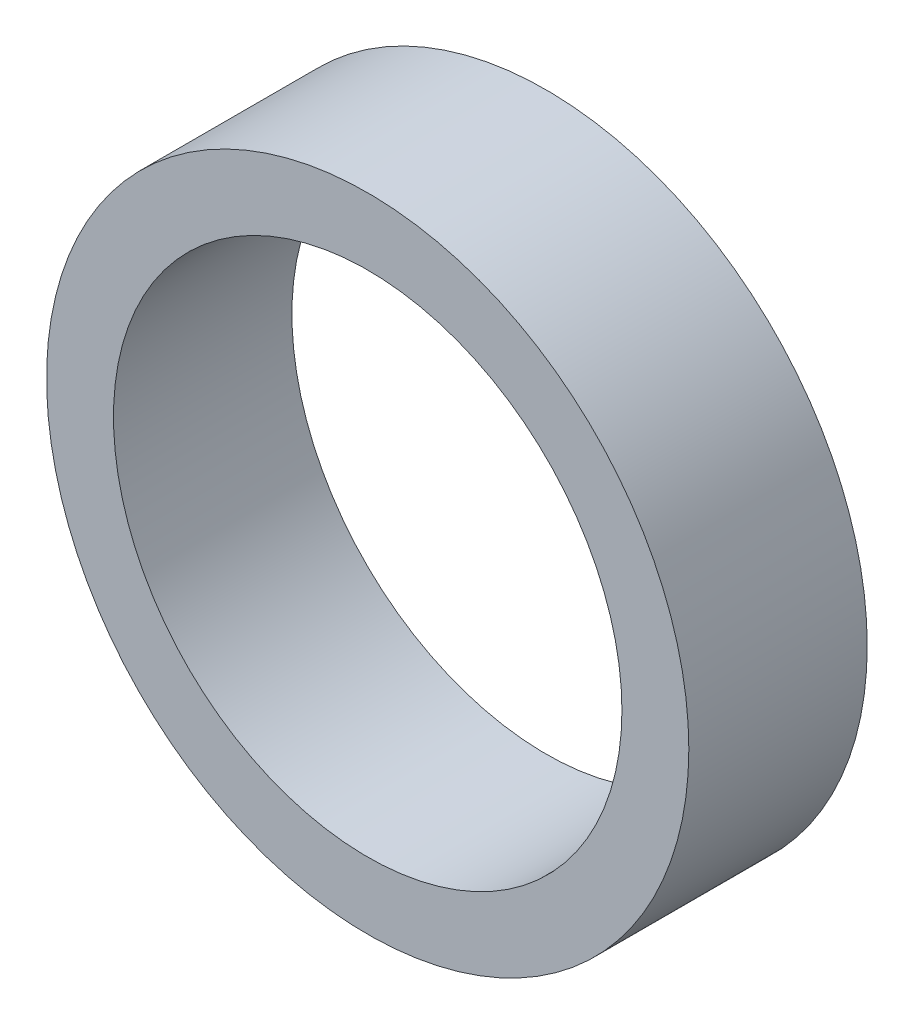
from build123d import *

# Parameters (mm, degrees)
ESQUISSE1_R      = 18
ESQUISSE1_R_2    = 14.25
EXTRUSION1_DEPTH = 5


with BuildPart() as part:
    # Esquisse1 → Extrusion1 (new body, symmetric)
    with BuildSketch(Plane.XY):
        Circle(ESQUISSE1_R)
        Circle(ESQUISSE1_R_2, mode=Mode.SUBTRACT)
    extrude(amount=EXTRUSION1_DEPTH, both=True)


solid = part.part
